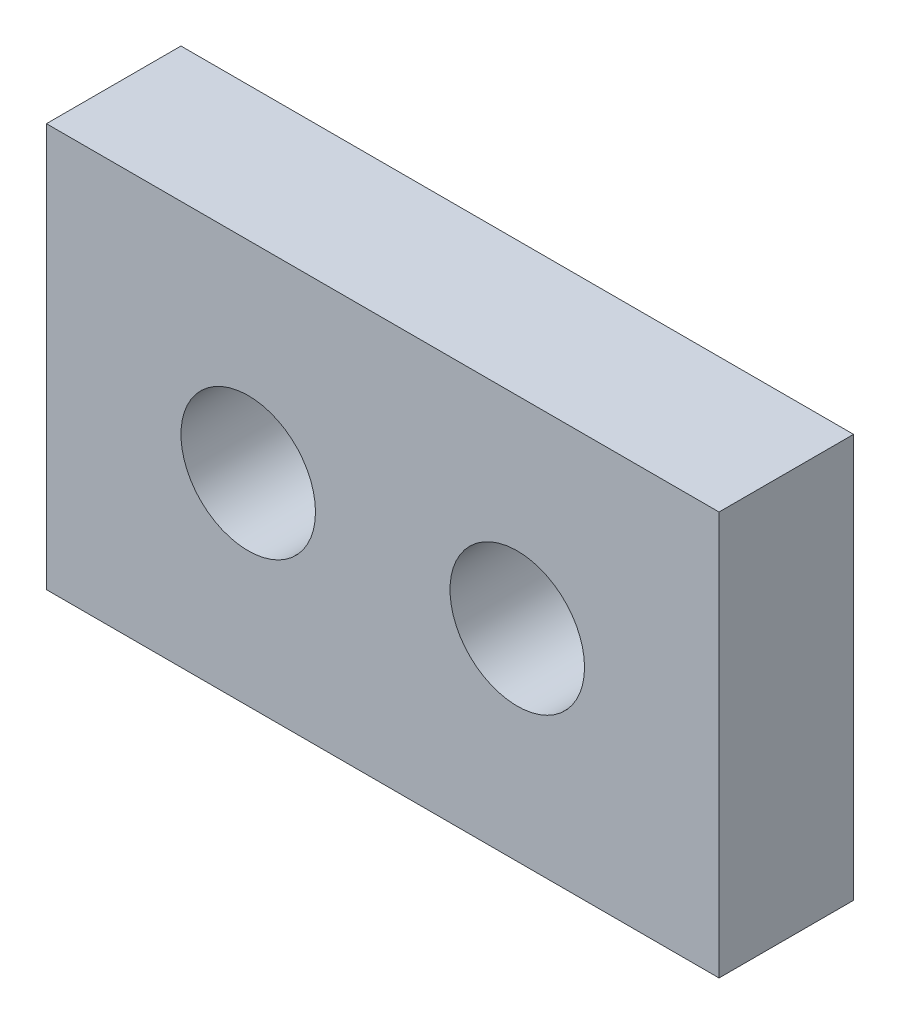
from build123d import *

# Parameters (mm, degrees)
SKETCH1_W           = 50
SKETCH1_H           = 30
BOSS_EXTRUDE1_DEPTH = 10
SKETCH2_R           = 5
CUT_EXTRUDE1_DEPTH  = 11


with BuildPart() as part:
    # Sketch1 → Boss-Extrude1 (new body)
    with BuildSketch(Plane.XY):
        with Locations((25, 15)):
            Rectangle(SKETCH1_W, SKETCH1_H)
    extrude(amount=BOSS_EXTRUDE1_DEPTH)

    # Sketch2 → Cut-Extrude1 (cut, through all)
    with BuildSketch(Plane.XY.offset(10)):
        with Locations((15, 15)):
            Circle(SKETCH2_R)
        with Locations((35, 15)):
            Circle(SKETCH2_R)
    extrude(amount=-CUT_EXTRUDE1_DEPTH, mode=Mode.SUBTRACT)


solid = part.part
